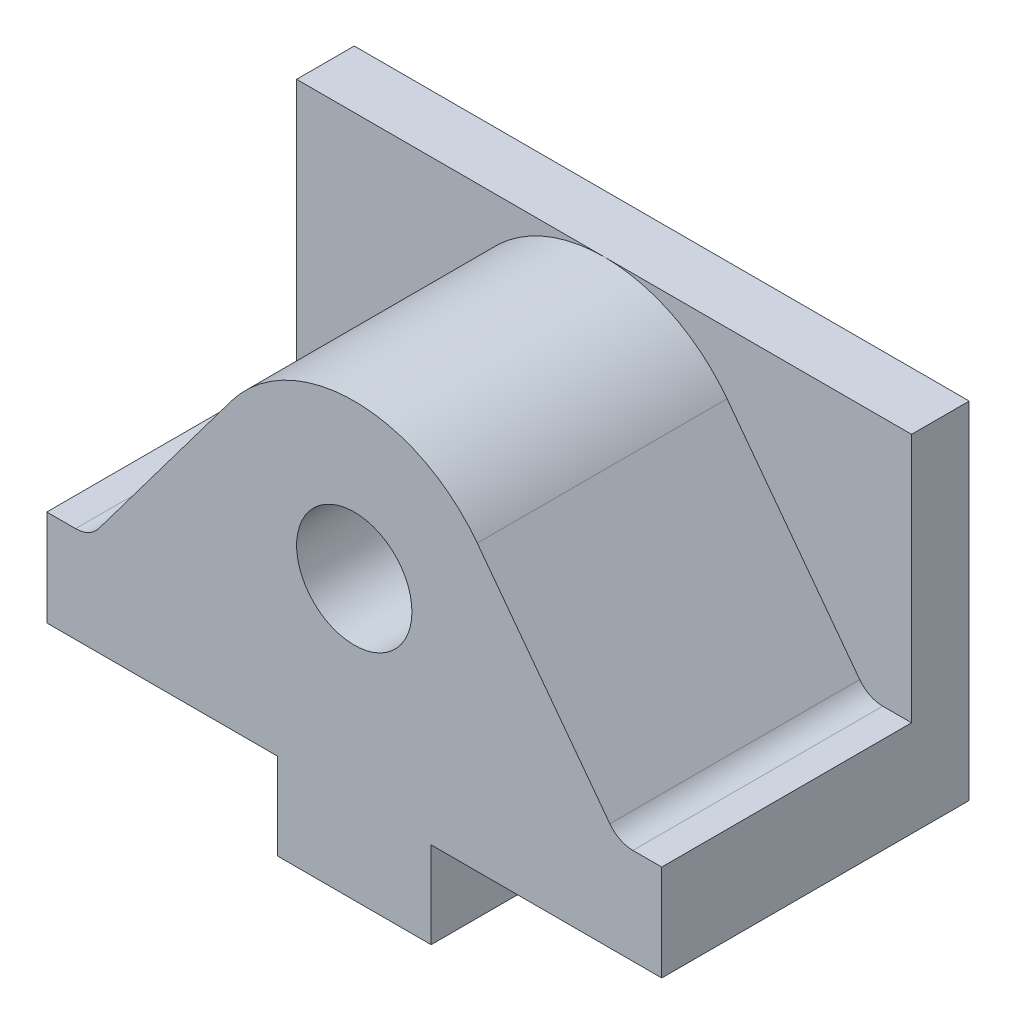
from build123d import *

# Parameters (mm, degrees)
SKETCH1_W           = 64
SKETCH1_H           = 32
BOSS_EXTRUDE1_DEPTH = 36
SKETCH3_R           = 6
CUT_EXTRUDE1_DEPTH  = 26
SKETCH4_R           = 6
CUT_EXTRUDE2_DEPTH  = 26
SKETCH5_W           = 16
SKETCH5_H           = 32
BOSS_EXTRUDE3_DEPTH = 9


with BuildPart() as part:
    # Sketch1 → Boss-Extrude1 (new body)
    with BuildSketch(Plane(origin=(0, 0, 0), x_dir=(1, 0, 0), z_dir=(0, 1, 0))):
        Rectangle(SKETCH1_W, SKETCH1_H)
    extrude(amount=BOSS_EXTRUDE1_DEPTH)

    # Sketch3 → Cut-Extrude1 (cut)
    with BuildSketch(Plane.XY.offset(16)):
        with BuildLine():
            Line((-32, 36), (-32, 10))
            Line((-32, 10), (-29, 10))
            ThreePointArc((-29, 10), (-27.658359214, 10.316718427), (-26.6, 11.2))
            Line((-26.6, 11.2), (-12.8, 29.6))
            ThreePointArc((-12.8, 29.6), (-7.155417528, 34.310835056), (0, 36))
            Line((0, 36), (-32, 36))
        make_face()
        with Locations((0, 20)):
            Circle(SKETCH3_R)
        with BuildLine():
            Line((32, 36), (0, 36))
            ThreePointArc((0, 36), (7.155417528, 34.310835056), (12.8, 29.6))
            Line((12.8, 29.6), (26.6, 11.2))
            ThreePointArc((26.6, 11.2), (27.658359214, 10.316718427), (29, 10))
            Line((29, 10), (32, 10))
            Line((32, 10), (32, 36))
        make_face()
    extrude(amount=-CUT_EXTRUDE1_DEPTH, mode=Mode.SUBTRACT)

    # Sketch4 → Cut-Extrude2 (cut)
    with BuildSketch(Plane.XY.offset(-10)):
        with Locations((0, 20)):
            Circle(SKETCH4_R)
    extrude(amount=-CUT_EXTRUDE2_DEPTH, mode=Mode.SUBTRACT)

    # Sketch5 → Boss-Extrude3 (add)
    with BuildSketch(Plane.XZ):
        Rectangle(SKETCH5_W, SKETCH5_H)
    extrude(amount=BOSS_EXTRUDE3_DEPTH)


solid = part.part
